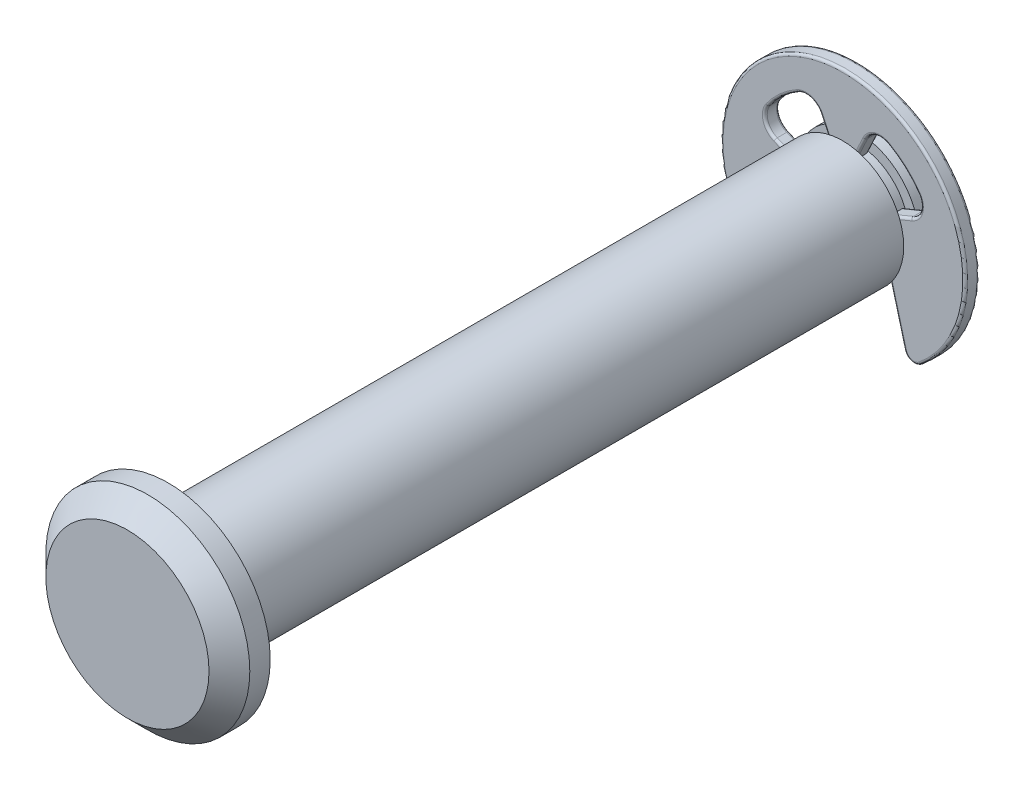
from build123d import *

# Parameters (mm, degrees)
BOSS_EXTRUDE1_DEPTH      = 0.35
BOSS_EXTRUDE1_DEPTH_BACK = 0.35
FILLET1_R                = 0.12
CHAMFER1_SIZE            = 0.6


with BuildPart() as part:
    # Sketch2 → Revolve1 (revolve)
    with BuildSketch(Plane(origin=(0, 0, 0), x_dir=(0, 0, -1), z_dir=(1, 0, 0))):
        Polygon((17.5, 3), (17.5, 0), (-19.5, 0), (-19.5, 4), (-18.5, 5), (-17.5, 5), (-17.5, 3), (15.56, 3), (15.56, 2.5), (16.3, 2.5), (16.3, 3), align=None)
    revolve(axis=Axis((0, 0, 17.5), (0, 0, -1)))

    # Chamfer1
    chamfer1_edges = [part.edges().sort_by_distance(p)[0] for p in [
        (0, -3, -17.5),
    ]]
    chamfer(chamfer1_edges, length=CHAMFER1_SIZE)


with BuildPart() as body_2:
    # Sketch3 → Boss-Extrude1 (new body, two sides)
    with BuildSketch(Plane(origin=(0, 0, -15.93), x_dir=(-1, 0, 0), z_dir=(0, 0, -1))) as boss_extrude1_sk:
        with BuildLine():
            ThreePointArc((-2.211302211, 3.919201772), (-1.573842768, 3.984228004), (-1.093135589, 3.5605494))
            Line((-1.093135589, 3.5605494), (-0.568095803, 2.434597946))
            ThreePointArc((-0.568095803, 2.434597946), (0, 2.5), (0.568095803, 2.434597946))
            Line((0.568095803, 2.434597946), (1.093135589, 3.5605494))
            ThreePointArc((1.093135589, 3.5605494), (1.573842768, 3.984228004), (2.211302211, 3.919201772))
            ThreePointArc((2.211302211, 3.919201772), (3.024074317, 3.332412718), (3.686774698, 2.580250438))
            ThreePointArc((3.686774698, 2.580250438), (3.799362352, 1.89758817), (3.337494831, 1.382435623))
            Line((3.337494831, 1.382435623), (2.309698831, 0.956708581))
            ThreePointArc((2.309698831, 0.956708581), (2.451963201, 0.487725805), (2.5, 0))
            ThreePointArc((2.5, 0), (2.41386496, -0.650581242), (2.161395238, -1.256332211))
            Line((2.161395238, -1.256332211), (3, -4.386047791))
            ThreePointArc((3, -4.386047791), (3.329664547, -4.732558021), (3.799595905, -4.643605383))
            ThreePointArc((3.799595905, -4.643605383), (5.422064894, -2.569282445), (6, 0))
            ThreePointArc((6, 0), (-2.569282445, 5.422064894), (-3.799595905, -4.643605383))
            ThreePointArc((-3.799595905, -4.643605383), (-3.329664547, -4.732558021), (-3, -4.386047791))
            Line((-3, -4.386047791), (-2.161395238, -1.256332211))
            ThreePointArc((-2.161395238, -1.256332211), (-2.494405326, -0.167158813), (-2.309698831, 0.956708581))
            Line((-2.309698831, 0.956708581), (-3.337494831, 1.382435623))
            ThreePointArc((-3.337494831, 1.382435623), (-3.799362352, 1.89758817), (-3.686774698, 2.580250438))
            ThreePointArc((-3.686774698, 2.580250438), (-3.024074317, 3.332412718), (-2.211302211, 3.919201772))
        make_face()
    extrude(amount=BOSS_EXTRUDE1_DEPTH)
    extrude(boss_extrude1_sk.sketch, amount=-BOSS_EXTRUDE1_DEPTH_BACK)

    # Fillet1
    fillet1_edges = [body_2.edges().sort_by_distance(p)[0] for p in [
        (3.329664547, -4.732558021, -16.28),
        (2.580697619, -2.821190001, -16.28),
        (2.494405326, -0.167158813, -16.28),
        (2.823596831, 1.169572102, -16.28),
        (3.799362352, 1.89758817, -16.28),
        (3.024074317, 3.332412718, -16.28),
        (1.573842768, 3.984228004, -16.28),
        (0.830615696, 2.997573673, -16.28),
        (0, 2.5, -16.28),
        (-3.329664547, -4.732558021, -15.58),
        (-2.580697619, -2.821190001, -15.58),
        (-2.823596831, 1.169572102, -15.58),
        (-0.830615696, 2.997573673, -15.58),
        (-3.329664547, -4.732558021, -16.28),
        (-0.830615696, 2.997573673, -16.28),
        (0.830615696, 2.997573673, -15.58),
        (2.823596831, 1.169572102, -15.58),
        (2.580697619, -2.821190001, -15.58),
        (-1.573842768, 3.984228004, -16.28),
        (3.329664547, -4.732558021, -15.58),
        (0, 6, -15.58),
        (-2.494405326, -0.167158813, -15.58),
        (-3.799362352, 1.89758817, -15.58),
        (-3.024074317, 3.332412718, -15.58),
        (-1.573842768, 3.984228004, -15.58),
        (0, 2.5, -15.58),
        (1.573842768, 3.984228004, -15.58),
        (3.024074317, 3.332412718, -15.58),
        (-3.024074317, 3.332412718, -16.28),
        (3.799362352, 1.89758817, -15.58),
        (2.494405326, -0.167158813, -15.58),
        (-3.799362352, 1.89758817, -16.28),
        (-2.823596831, 1.169572102, -16.28),
        (-2.494405326, -0.167158813, -16.28),
        (-2.580697619, -2.821190001, -16.28),
        (0, 6, -16.28),
    ]]
    fillet(fillet1_edges, radius=FILLET1_R)


solid = Compound([part.part, body_2.part])
